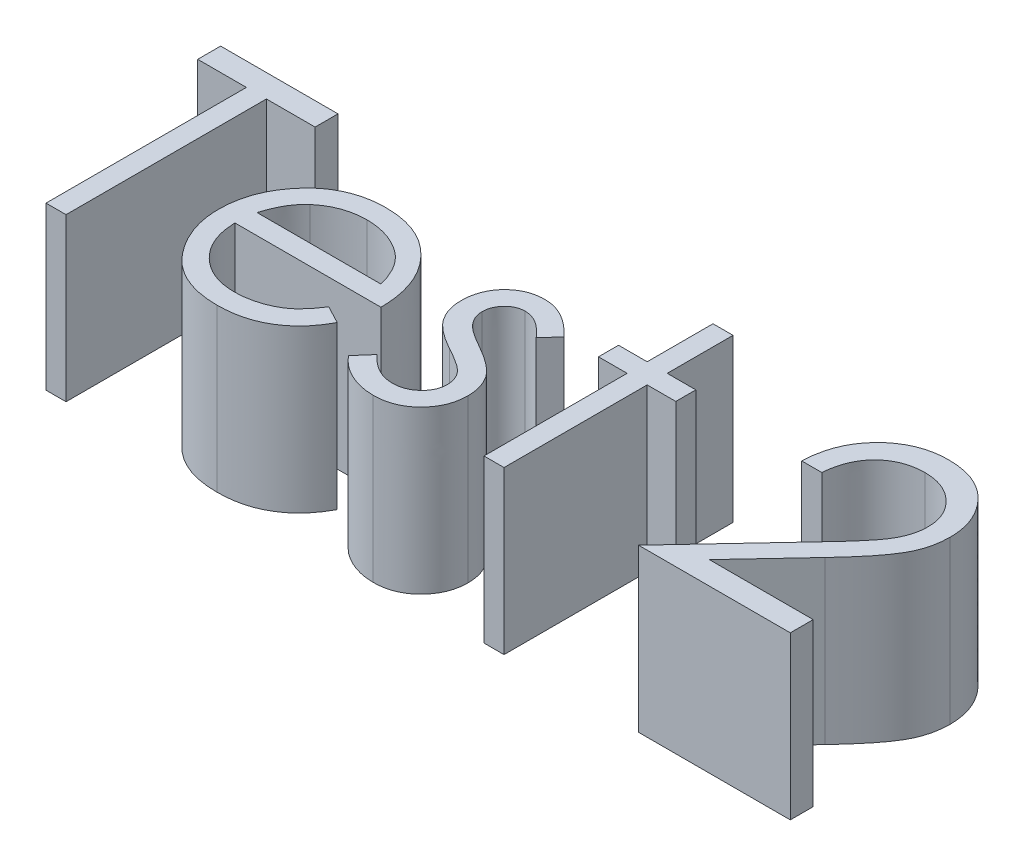
from build123d import *

# Parameters (mm, degrees)
BOSS_EXTRUDE1_DEPTH   = 2.54
BOSS_EXTRUDE1_2_DEPTH = 2.54
BOSS_EXTRUDE1_3_DEPTH = 2.54
BOSS_EXTRUDE1_4_DEPTH = 2.54
BOSS_EXTRUDE1_5_DEPTH = 2.54


with BuildPart() as part:
    # Sketch2 → Boss-Extrude1 (new body)
    with BuildSketch(Plane(origin=(0, 0, 0), x_dir=(1, 0, 0), z_dir=(0, 1, 0))):
        Polygon((-4.824988358, 3.141025641), (-4.824988358, 3.5), (-2.985244769, 3.5), (-2.985244769, 3.141025641), (-3.748065281, 3.141025641), (-3.748065281, 0), (-4.062167846, 0), (-4.062167846, 3.141025641), align=None)
    extrude(amount=BOSS_EXTRUDE1_DEPTH)


with BuildPart() as body_2:
    # Sketch2 → Boss-Extrude1 2 (new body)
    with BuildSketch(Plane(origin=(0, 0, 0), x_dir=(1, 0, 0), z_dir=(0, 1, 0))):
        with BuildLine():
            Line((-0.437368166, 0.807692308), (-0.158321692, 0.661157853))
            add(Edge.make_bspline(
                [(-0.158321692, 0.661157853), (-0.180558287, 0.621714521), (-0.223821895, 0.544973418), (-0.298222643, 0.439541558), (-0.376214716, 0.344693842), (-0.461318684, 0.262964188), (-0.550988363, 0.191712803), (-0.645721018, 0.129374978), (-0.746009835, 0.076256458), (-0.85185956, 0.03150393), (-0.964159111, -0.002905564), (-1.083180628, -0.027209785), (-1.209152123, -0.042233054), (-1.295498303, -0.043978194), (-1.339711916, -0.044871795)],
                knots=[0, 0, 0, 0, 0.000135759, 0.000264133, 0.000386579, 0.000503597, 0.000617365, 0.000729763, 0.000843304, 0.000957371, 0.001074023, 0.001195027, 0.001321389, 0.001453992, 0.001453992, 0.001453992, 0.001453992], degree=3))
            add(Edge.make_bspline(
                [(-1.339711916, -0.044871795), (-1.388853894, -0.04372462), (-1.484715655, -0.041486813), (-1.624255402, -0.022194348), (-1.755634821, 0.00927801), (-1.878846524, 0.053243552), (-1.993588777, 0.110670876), (-2.100089631, 0.180630358), (-2.198909157, 0.262762612), (-2.286933367, 0.357779056), (-2.366177249, 0.459461013), (-2.436103069, 0.565416898), (-2.4945605, 0.675380122), (-2.54211311, 0.788650646), (-2.580517975, 0.90451454), (-2.607284679, 1.024026007), (-2.622714427, 1.146861592), (-2.625078873, 1.229958927), (-2.62627041, 1.271834936)],
                knots=[0, 0, 0, 0, 0.000147371, 0.000287478, 0.000421649, 0.000552053, 0.000679042, 0.000805636, 0.000933558, 0.00106351, 0.001193382, 0.001319977, 0.001443869, 0.001566405, 0.001688128, 0.001809576, 0.001933238, 0.002058864, 0.002058864, 0.002058864, 0.002058864], degree=3))
            add(Edge.make_bspline(
                [(-2.62627041, 1.271834936), (-2.625211268, 1.311129766), (-2.62311219, 1.389006931), (-2.609881403, 1.504272476), (-2.58643311, 1.616300928), (-2.554256786, 1.725185376), (-2.512705539, 1.83074351), (-2.46187332, 1.933039574), (-2.401680942, 2.031964713), (-2.355208269, 2.094367847), (-2.331799256, 2.125801282)],
                knots=[0, 0, 0, 0, 0.000117891, 0.000233644, 0.000347498, 0.000460856, 0.000573868, 0.000687374, 0.000803169, 0.000920699, 0.000920699, 0.000920699, 0.000920699], degree=3))
            add(Edge.make_bspline(
                [(-2.331799256, 2.125801282), (-2.300091573, 2.163670152), (-2.237680626, 2.238208303), (-2.132124271, 2.336146628), (-2.017824075, 2.418190404), (-1.896212449, 2.48619754), (-1.765875975, 2.537871187), (-1.628566684, 2.576378769), (-1.482721097, 2.59795678), (-1.383015876, 2.601004614), (-1.331999576, 2.602564103)],
                knots=[0, 0, 0, 0, 0.000148071, 0.000291452, 0.00043058, 0.000569298, 0.000708346, 0.00085021, 0.000996268, 0.001149307, 0.001149307, 0.001149307, 0.001149307], degree=3))
            add(Edge.make_bspline(
                [(-1.331999576, 2.602564103), (-1.279551971, 2.601210054), (-1.176661725, 2.598553718), (-1.026629604, 2.573927385), (-0.884668887, 2.53487483), (-0.750836383, 2.47972104), (-0.625118522, 2.408561488), (-0.508332473, 2.320419647), (-0.39848096, 2.218001559), (-0.334572381, 2.13923835), (-0.30205166, 2.099158654)],
                knots=[0, 0, 0, 0, 0.000157241, 0.00030847, 0.000454763, 0.000598116, 0.000741606, 0.000886879, 0.001036172, 0.001190853, 0.001190853, 0.001190853, 0.001190853], degree=3))
            add(Edge.make_bspline(
                [(-0.30205166, 2.099158654), (-0.279924721, 2.068955072), (-0.235818128, 2.008748954), (-0.180571028, 1.910577797), (-0.132613633, 1.807867202), (-0.094280672, 1.698956905), (-0.063241171, 1.585137325), (-0.040784352, 1.46559478), (-0.027614734, 1.340364869), (-0.025026036, 1.255038314), (-0.023706307, 1.211538462)],
                knots=[0, 0, 0, 0, 0.000112234, 0.000223721, 0.000337279, 0.000451932, 0.000569628, 0.000690912, 0.000816421, 0.00094695, 0.00094695, 0.00094695, 0.00094695], degree=3))
            Line((-0.023706307, 1.211538462), (-2.312167846, 1.211538462))
            add(Edge.make_bspline(
                [(-2.312167846, 1.211538462), (-2.310628239, 1.177837997), (-2.307600665, 1.111567394), (-2.293485522, 1.01459661), (-2.271236748, 0.922223268), (-2.239967686, 0.835140226), (-2.20210084, 0.752210099), (-2.155715124, 0.674048062), (-2.10037557, 0.601010132), (-2.03864987, 0.532442994), (-1.969942775, 0.471382233), (-1.897660028, 0.416730457), (-1.820766463, 0.37092486), (-1.739868379, 0.33374497), (-1.655096594, 0.304638654), (-1.566424399, 0.284770834), (-1.474026283, 0.271463727), (-1.411040549, 0.269984061), (-1.378974737, 0.269230769)],
                knots=[0, 0, 0, 0, 0.000101159, 0.000198924, 0.000293472, 0.000385722, 0.000476069, 0.000566611, 0.000657757, 0.000750573, 0.000842919, 0.000933083, 0.001022062, 0.001110842, 0.001199752, 0.001290403, 0.001383113, 0.001479259, 0.001479259, 0.001479259, 0.001479259], degree=3))
            add(Edge.make_bspline(
                [(-1.378974737, 0.269230769), (-1.347623589, 0.269838826), (-1.285416898, 0.271045327), (-1.192776041, 0.282777238), (-1.101636513, 0.301747513), (-1.01237553, 0.327637504), (-0.926804684, 0.359214356), (-0.847559134, 0.397317213), (-0.774678918, 0.43946696), (-0.706561952, 0.487676635), (-0.640490958, 0.546684822), (-0.574948472, 0.620320543), (-0.504671819, 0.707408071), (-0.460682226, 0.772953737), (-0.437368166, 0.807692308)],
                knots=[0, 0, 0, 0, 9.4016e-05, 0.000186545, 0.000279636, 0.000373054, 0.000465125, 0.000552934, 0.000636508, 0.000717442, 0.000802858, 0.000901616, 0.001012865, 0.001138311, 0.001138311, 0.001138311, 0.001138311], degree=3))
        make_face()
        with BuildLine():
            add(Edge.make_bspline(
                [(-0.337808871, 1.525641026), (-0.349305496, 1.567303899), (-0.371432797, 1.64749152), (-0.417669162, 1.75853241), (-0.469740702, 1.857220311), (-0.531362434, 1.942799944), (-0.601181159, 2.018803457), (-0.681826342, 2.085222043), (-0.772262235, 2.144639494), (-0.872021376, 2.194791993), (-0.977663161, 2.237481852), (-1.088269353, 2.266106968), (-1.201127141, 2.28571651), (-1.277461427, 2.287542618), (-1.315873775, 2.288461538)],
                knots=[0, 0, 0, 0, 0.000129543, 0.000249328, 0.000360065, 0.000463575, 0.000564789, 0.000668832, 0.000776175, 0.000888744, 0.001003316, 0.001117263, 0.001230914, 0.001346035, 0.001346035, 0.001346035, 0.001346035], degree=3))
            add(Edge.make_bspline(
                [(-1.315873775, 2.288461538), (-1.347223214, 2.287849867), (-1.409194463, 2.286640721), (-1.500495531, 2.275170592), (-1.58817523, 2.256210747), (-1.672880517, 2.23024579), (-1.753501386, 2.195637188), (-1.831696154, 2.155053961), (-1.90547655, 2.105512377), (-1.951617846, 2.067753522), (-1.974928262, 2.048677885)],
                knots=[0, 0, 0, 0, 9.4016e-05, 0.000185849, 0.000275511, 0.000362884, 0.000451173, 0.00053836, 0.000626838, 0.000717174, 0.000717174, 0.000717174, 0.000717174], degree=3))
            add(Edge.make_bspline(
                [(-1.974928262, 2.048677885), (-1.991621544, 2.033583569), (-2.025404678, 2.003036353), (-2.0705452, 1.950407146), (-2.113765673, 1.893655584), (-2.153099325, 1.83061046), (-2.189176912, 1.761989681), (-2.222936889, 1.688372045), (-2.253323301, 1.609198915), (-2.270419411, 1.554026476), (-2.279215121, 1.525641026)],
                knots=[0, 0, 0, 0, 6.7454e-05, 0.00013651, 0.000207604, 0.000281328, 0.000359112, 0.000440057, 0.000524171, 0.000613305, 0.000613305, 0.000613305, 0.000613305], degree=3))
            Line((-2.279215121, 1.525641026), (-0.337808871, 1.525641026))
        make_face(mode=Mode.SUBTRACT)
    extrude(amount=BOSS_EXTRUDE1_2_DEPTH)


with BuildPart() as body_3:
    # Sketch2 → Boss-Extrude1 3 (new body)
    with BuildSketch(Plane(origin=(0, 0, 0), x_dir=(1, 0, 0), z_dir=(0, 1, 0))):
        with BuildLine():
            Line((1.816037283, 2.238681891), (1.602896257, 2.019230769))
            add(Edge.make_bspline(
                [(1.602896257, 2.019230769), (1.584505754, 2.040543916), (1.549051028, 2.081633153), (1.492819547, 2.136570219), (1.436795943, 2.182707158), (1.38174713, 2.221659417), (1.32628886, 2.251108564), (1.271071942, 2.272603426), (1.216039204, 2.285905231), (1.179253169, 2.28761967), (1.161189526, 2.288461538)],
                knots=[0, 0, 0, 0, 8.4426e-05, 0.000162764, 0.000235478, 0.000301992, 0.000364722, 0.000423315, 0.00047944, 0.00053359, 0.00053359, 0.00053359, 0.00053359], degree=3))
            add(Edge.make_bspline(
                [(1.161189526, 2.288461538), (1.139050136, 2.287386665), (1.09548295, 2.285271468), (1.033057132, 2.264158037), (0.975106507, 2.231749299), (0.924949527, 2.185780715), (0.882461847, 2.133016446), (0.851448166, 2.074020122), (0.832482182, 2.010572078), (0.83007745, 1.96654222), (0.828857796, 1.944210737)],
                knots=[0, 0, 0, 0, 6.6207e-05, 0.000130286, 0.000195595, 0.000264126, 0.000333001, 0.000397918, 0.000462926, 0.000529831, 0.000529831, 0.000529831, 0.000529831], degree=3))
            add(Edge.make_bspline(
                [(0.828857796, 1.944210737), (0.829968608, 1.923998693), (0.832187101, 1.883631582), (0.84943378, 1.824083548), (0.876899852, 1.76602651), (0.902570047, 1.730463604), (0.915796898, 1.712139423)],
                knots=[0, 0, 0, 0, 6.0557e-05, 0.000120943, 0.000184606, 0.000252278, 0.000252278, 0.000252278, 0.000252278], degree=3))
            add(Edge.make_bspline(
                [(0.915796898, 1.712139423), (0.923760392, 1.702354839), (0.940709685, 1.681529584), (0.9725182, 1.652625731), (1.008540702, 1.62068348), (1.05186064, 1.588746643), (1.100611668, 1.555114918), (1.155850952, 1.521112785), (1.215825457, 1.48414836), (1.258762764, 1.460703924), (1.281081353, 1.448517628)],
                knots=[0, 0, 0, 0, 3.7796e-05, 8.0443e-05, 0.000128658, 0.000182224, 0.000241732, 0.000306315, 0.000376777, 0.000453048, 0.000453048, 0.000453048, 0.000453048], degree=3))
            add(Edge.make_bspline(
                [(1.281081353, 1.448517628), (1.30829493, 1.433272725), (1.3608626, 1.403824593), (1.435555368, 1.358114889), (1.503342409, 1.312683465), (1.564798076, 1.268016191), (1.618739885, 1.222863324), (1.666804438, 1.178955567), (1.707792882, 1.134966258), (1.730746808, 1.104233145), (1.741718372, 1.089543269)],
                knots=[0, 0, 0, 0, 9.3573e-05, 0.000180752, 0.000262618, 0.000338343, 0.000408542, 0.000473535, 0.000533574, 0.000588549, 0.000588549, 0.000588549, 0.000588549], degree=3))
            add(Edge.make_bspline(
                [(1.741718372, 1.089543269), (1.7599289, 1.059877181), (1.796171229, 1.00083616), (1.834229496, 0.903617733), (1.85628977, 0.80050723), (1.859351991, 0.72997501), (1.860909078, 0.694110577)],
                knots=[0, 0, 0, 0, 0.000104269, 0.000207515, 0.000311475, 0.000419024, 0.000419024, 0.000419024, 0.000419024], degree=3))
            add(Edge.make_bspline(
                [(1.860909078, 0.694110577), (1.860189544, 0.668841431), (1.858771624, 0.619045818), (1.848913557, 0.545710988), (1.83195858, 0.47557643), (1.808864827, 0.407881146), (1.777680454, 0.343922206), (1.741132656, 0.282085957), (1.697257745, 0.223710026), (1.647166369, 0.168871066), (1.592320875, 0.118785319), (1.533814737, 0.074761365), (1.471575906, 0.038187028), (1.406049105, 0.007921682), (1.337085451, -0.016146576), (1.264674161, -0.032809107), (1.189045407, -0.042781868), (1.137615599, -0.044166344), (1.111409879, -0.044871795)],
                knots=[0, 0, 0, 0, 7.5802e-05, 0.000149377, 0.00022148, 0.00029199, 0.000363491, 0.000434554, 0.00050719, 0.000582132, 0.000657073, 0.000729709, 0.000801375, 0.000873212, 0.000945939, 0.001020089, 0.001095749, 0.001174353, 0.001174353, 0.001174353, 0.001174353], degree=3))
            add(Edge.make_bspline(
                [(1.111409879, -0.044871795), (1.076042703, -0.043879095), (1.005799776, -0.041907487), (0.901910057, -0.023401426), (0.800389299, 0.005393968), (0.702005758, 0.045109902), (0.608959644, 0.095260615), (0.52382872, 0.155323008), (0.446317257, 0.223313006), (0.402198984, 0.275425916), (0.380139847, 0.301482372)],
                knots=[0, 0, 0, 0, 0.000106018, 0.000210563, 0.000315537, 0.000422167, 0.000528204, 0.00063188, 0.000734181, 0.000836482, 0.000836482, 0.000836482, 0.000836482], degree=3))
            Line((0.380139847, 0.301482372), (0.58837302, 0.538461538))
            add(Edge.make_bspline(
                [(0.58837302, 0.538461538), (0.608145433, 0.517106774), (0.646477245, 0.475707334), (0.707778462, 0.420582993), (0.770157863, 0.374381722), (0.83299255, 0.335738307), (0.897212644, 0.305962904), (0.962458258, 0.28504431), (1.028596682, 0.271600118), (1.073018818, 0.270021836), (1.095284078, 0.269230769)],
                knots=[0, 0, 0, 0, 8.7278e-05, 0.000169201, 0.000246886, 0.000319874, 0.000390144, 0.000458657, 0.000525071, 0.00059181, 0.00059181, 0.00059181, 0.00059181], degree=3))
            add(Edge.make_bspline(
                [(1.095284078, 0.269230769), (1.125602004, 0.270601594), (1.184838145, 0.273279956), (1.269681904, 0.297597048), (1.34802053, 0.335727), (1.416043876, 0.389811698), (1.473946037, 0.452767271), (1.515874211, 0.52368139), (1.542150387, 0.600472847), (1.545236385, 0.653705149), (1.546806513, 0.680789263)],
                knots=[0, 0, 0, 0, 9.0773e-05, 0.000177355, 0.000262642, 0.000350576, 0.00043646, 0.000517865, 0.000596131, 0.000677197, 0.000677197, 0.000677197, 0.000677197], degree=3))
            add(Edge.make_bspline(
                [(1.546806513, 0.680789263), (1.545720219, 0.703098881), (1.543575476, 0.747146237), (1.526732204, 0.810896578), (1.500119352, 0.871365859), (1.473914704, 0.906755506), (1.460568533, 0.924779647)],
                knots=[0, 0, 0, 0, 6.6842e-05, 0.000131971, 0.000196611, 0.000263703, 0.000263703, 0.000263703, 0.000263703], degree=3))
            add(Edge.make_bspline(
                [(1.460568533, 0.924779647), (1.452546138, 0.93381501), (1.435070466, 0.953497292), (1.403015225, 0.98192237), (1.364633362, 1.01256047), (1.319493199, 1.044892059), (1.267503737, 1.078490664), (1.208454262, 1.113180016), (1.14315371, 1.150607742), (1.096983078, 1.175427397), (1.07284818, 1.188401442)],
                knots=[0, 0, 0, 0, 3.6222e-05, 7.8904e-05, 0.000128287, 0.000183547, 0.000245389, 0.000313927, 0.000388976, 0.000471175, 0.000471175, 0.000471175, 0.000471175], degree=3))
            add(Edge.make_bspline(
                [(1.07284818, 1.188401442), (1.04680154, 1.202940574), (0.996288793, 1.23113659), (0.924741502, 1.275052671), (0.860194147, 1.319719945), (0.801093573, 1.362632784), (0.748932567, 1.406053728), (0.703916619, 1.45003098), (0.664273403, 1.492790966), (0.642325991, 1.523088263), (0.631842571, 1.537560096)],
                knots=[0, 0, 0, 0, 8.9486e-05, 0.000173541, 0.000251719, 0.000324918, 0.000392605, 0.000455079, 0.000513655, 0.000567221, 0.000567221, 0.000567221, 0.000567221], degree=3))
            add(Edge.make_bspline(
                [(0.631842571, 1.537560096), (0.613711971, 1.566705711), (0.577444436, 1.625007126), (0.542229245, 1.722317603), (0.518023216, 1.824762661), (0.515860826, 1.895449515), (0.514755231, 1.931590545)],
                knots=[0, 0, 0, 0, 0.000102704, 0.000205444, 0.000308869, 0.000417069, 0.000417069, 0.000417069, 0.000417069], degree=3))
            add(Edge.make_bspline(
                [(0.514755231, 1.931590545), (0.515289427, 1.955215943), (0.516334923, 2.001454194), (0.524678974, 2.069393014), (0.539870685, 2.133941168), (0.558925608, 2.196068031), (0.585408612, 2.254570125), (0.617054518, 2.310227596), (0.654241943, 2.362963514), (0.697085233, 2.411966646), (0.744191879, 2.456475972), (0.795086648, 2.4952746), (0.848624905, 2.528380955), (0.905033325, 2.556146116), (0.964853797, 2.577147498), (1.027668184, 2.591604883), (1.093349339, 2.601260086), (1.138250465, 2.602123171), (1.161189526, 2.602564103)],
                knots=[0, 0, 0, 0, 7.0869e-05, 0.0001387, 0.000204863, 0.000269609, 0.000333323, 0.000397067, 0.000461456, 0.000526554, 0.000592026, 0.00065555, 0.000718201, 0.000780601, 0.000843799, 0.000907913, 0.000973751, 0.001042518, 0.001042518, 0.001042518, 0.001042518], degree=3))
            add(Edge.make_bspline(
                [(1.161189526, 2.602564103), (1.18838159, 2.601459762), (1.243275812, 2.599230364), (1.325630438, 2.581524674), (1.40786378, 2.552391569), (1.49018713, 2.512155336), (1.571997419, 2.46008846), (1.654014276, 2.397159161), (1.737222306, 2.323781446), (1.789178619, 2.267682221), (1.816037283, 2.238681891)],
                knots=[0, 0, 0, 0, 8.1523e-05, 0.000164576, 0.000251498, 0.000342746, 0.000438841, 0.000541908, 0.000652652, 0.000771167, 0.000771167, 0.000771167, 0.000771167], degree=3))
        make_face()
    extrude(amount=BOSS_EXTRUDE1_3_DEPTH)


with BuildPart() as body_4:
    # Sketch2 → Boss-Extrude1 4 (new body)
    with BuildSketch(Plane(origin=(0, 0, 0), x_dir=(1, 0, 0), z_dir=(0, 1, 0))):
        Polygon((2.80321677, 3.58974359), (3.117319334, 3.58974359), (3.117319334, 2.557692308), (3.566037283, 2.557692308), (3.566037283, 2.243589744), (3.117319334, 2.243589744), (3.117319334, 0), (2.80321677, 0), (2.80321677, 2.243589744), (2.354498821, 2.243589744), (2.354498821, 2.557692308), (2.80321677, 2.557692308), align=None)
    extrude(amount=BOSS_EXTRUDE1_4_DEPTH)


with BuildPart() as body_5:
    # Sketch2 → Boss-Extrude1 5 (new body)
    with BuildSketch(Plane(origin=(0, 0, 0), x_dir=(1, 0, 0), z_dir=(0, 1, 0))):
        with BuildLine():
            Line((5.675011642, 2.423076923), (5.360909078, 2.423076923))
            add(Edge.make_bspline(
                [(5.360909078, 2.423076923), (5.362956231, 2.464747811), (5.366976785, 2.546588325), (5.385805074, 2.665912232), (5.412745951, 2.779967031), (5.450837405, 2.887836945), (5.498143683, 2.990475752), (5.55487371, 3.087475767), (5.622067561, 3.178466956), (5.698274295, 3.262605799), (5.781042934, 3.33979337), (5.870348873, 3.406448613), (5.964193901, 3.462766284), (6.0622933, 3.509847526), (6.165753863, 3.545187372), (6.273636721, 3.571409012), (6.386415857, 3.587185357), (6.463255879, 3.588881143), (6.50233536, 3.58974359)],
                knots=[0, 0, 0, 0, 0.000125083, 0.00024566, 0.000361805, 0.000476223, 0.000588214, 0.000700404, 0.000812728, 0.00092691, 0.001040529, 0.001151727, 0.001260545, 0.001368429, 0.001477521, 0.001587884, 0.001701119, 0.00181831, 0.00181831, 0.00181831, 0.00181831], degree=3))
            add(Edge.make_bspline(
                [(6.50233536, 3.58974359), (6.540713434, 3.588845133), (6.616124978, 3.587079698), (6.726186993, 3.571918669), (6.830964287, 3.548173078), (6.930252054, 3.514857661), (7.023258118, 3.470073234), (7.110681163, 3.416275695), (7.193561974, 3.354055864), (7.268168757, 3.28080205), (7.336676837, 3.202599666), (7.395779092, 3.119111762), (7.446392255, 3.032882477), (7.488579935, 2.943254275), (7.519636074, 2.849383247), (7.543214282, 2.752636044), (7.556541696, 2.652011233), (7.558587119, 2.583904677), (7.559627026, 2.549278846)],
                knots=[0, 0, 0, 0, 0.000115089, 0.000226145, 0.000332614, 0.000437044, 0.000539592, 0.000641561, 0.000744629, 0.00084975, 0.000954621, 0.001056175, 0.001156101, 0.001254284, 0.001352726, 0.001452208, 0.001552655, 0.001656537, 0.001656537, 0.001656537, 0.001656537], degree=3))
            add(Edge.make_bspline(
                [(7.559627026, 2.549278846), (7.557940381, 2.500529037), (7.55459669, 2.403884909), (7.525740987, 2.261680551), (7.48115889, 2.123775492), (7.427085861, 2.01279644), (7.372465293, 1.923819547), (7.324285497, 1.849903905), (7.266633145, 1.771077489), (7.200035732, 1.68654638), (7.125497925, 1.59605201), (7.042483257, 1.499557244), (6.950357567, 1.398086939), (6.885699385, 1.328781126), (6.852195135, 1.29286859)],
                knots=[0, 0, 0, 0, 0.000146118, 0.000289672, 0.000433566, 0.000580006, 0.000658644, 0.000746735, 0.000844624, 0.000951498, 0.001069547, 0.001196319, 0.001333326, 0.00148067, 0.00148067, 0.00148067, 0.00148067], degree=3))
            Line((6.852195135, 1.29286859), (5.976494013, 0.358974359))
            Line((5.976494013, 0.358974359), (7.604498821, 0.358974359))
            Line((7.604498821, 0.358974359), (7.604498821, 0))
            Line((7.604498821, 0), (5.226293693, 0))
            Line((5.226293693, 0), (6.583665488, 1.448517628))
            add(Edge.make_bspline(
                [(6.583665488, 1.448517628), (6.616713375, 1.483015935), (6.680191602, 1.549280121), (6.769974179, 1.646023081), (6.850613167, 1.735772622), (6.92263056, 1.818359171), (6.984464065, 1.894990738), (7.039336297, 1.963185442), (7.083301888, 2.025939892), (7.131017284, 2.098680506), (7.177231265, 2.187492823), (7.216943621, 2.296026513), (7.241158469, 2.407753765), (7.244063305, 2.483255802), (7.245524462, 2.521233974)],
                knots=[0, 0, 0, 0, 0.000143319, 0.000275286, 0.00039593, 0.000505287, 0.000603949, 0.000691331, 0.000767782, 0.00083371, 0.000952247, 0.001067137, 0.001179618, 0.001293462, 0.001293462, 0.001293462, 0.001293462], degree=3))
            add(Edge.make_bspline(
                [(7.245524462, 2.521233974), (7.24488872, 2.545115373), (7.243635794, 2.592181023), (7.232578096, 2.661186782), (7.21586759, 2.727751596), (7.191922332, 2.792080215), (7.160315592, 2.853525867), (7.121842212, 2.912163347), (7.077452149, 2.968852313), (7.026100879, 3.022005611), (6.96968936, 3.070686816), (6.91009511, 3.113810902), (6.847045006, 3.149850012), (6.780804884, 3.179393509), (6.711559414, 3.202568891), (6.639174669, 3.21862747), (6.563850653, 3.228709954), (6.512417157, 3.230074126), (6.486209558, 3.230769231)],
                knots=[0, 0, 0, 0, 7.16e-05, 0.00014111, 0.00020913, 0.00027724, 0.000346538, 0.000415963, 0.000487357, 0.000562233, 0.000637292, 0.000710646, 0.000782564, 0.000854749, 0.000927915, 0.001001225, 0.001076884, 0.001155488, 0.001155488, 0.001155488, 0.001155488], degree=3))
            add(Edge.make_bspline(
                [(6.486209558, 3.230769231), (6.458838726, 3.230054199), (6.405086929, 3.228649993), (6.326167896, 3.218827329), (6.250882119, 3.201881489), (6.179040216, 3.178704814), (6.11052063, 3.149246266), (6.045656586, 3.112554521), (5.984593697, 3.068771028), (5.927217173, 3.019130471), (5.874353194, 2.96386287), (5.827906319, 2.902252907), (5.787322304, 2.835425492), (5.751913071, 2.763560941), (5.723157381, 2.686007161), (5.70118423, 2.603039456), (5.683797384, 2.515018075), (5.677988863, 2.45423299), (5.675011642, 2.423076923)],
                knots=[0, 0, 0, 0, 8.2106e-05, 0.000161243, 0.000238127, 0.000313291, 0.000387401, 0.000461495, 0.000536397, 0.000612445, 0.000688819, 0.000765383, 0.000843422, 0.000923066, 0.001005373, 0.001091093, 0.001180334, 0.001274175, 0.001274175, 0.001274175, 0.001274175], degree=3))
        make_face()
    extrude(amount=BOSS_EXTRUDE1_5_DEPTH)


solid = Compound([part.part, body_2.part, body_3.part, body_4.part, body_5.part])
